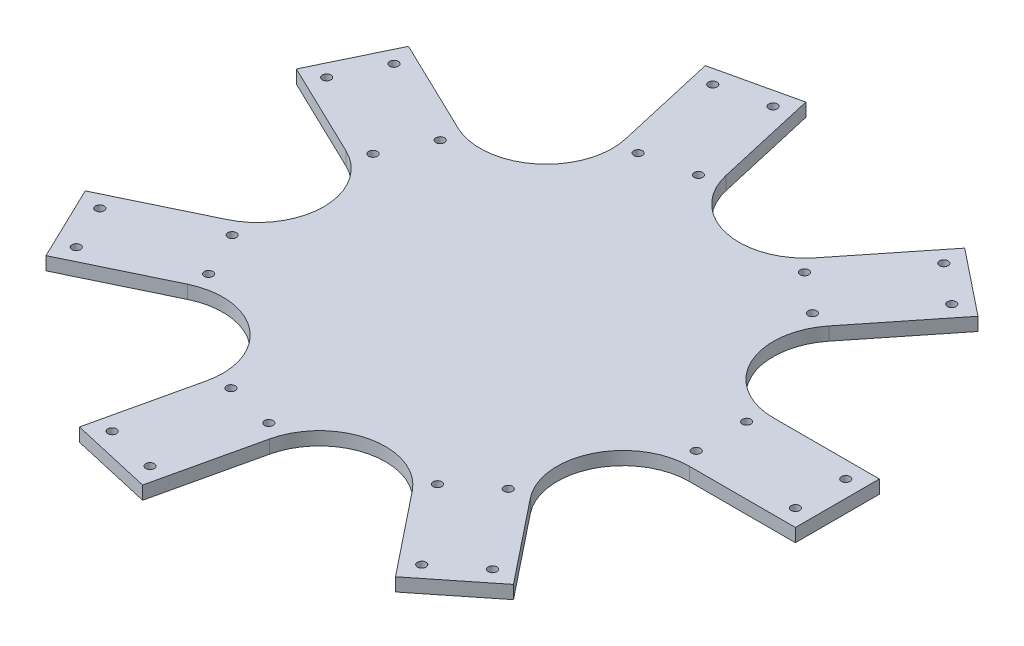
from build123d import *

# Parameters (mm, degrees)
SKETCH3_W           = 250
SKETCH3_H           = 63.5
SKETCH3_R           = 3.25
BOSS_EXTRUDE1_DEPTH = 10
CIRPATTERN1_COUNT   = 7
FILLET1_R           = 50


with BuildPart() as part:
    # Sketch3 → Boss-Extrude1 (new body)
    with BuildSketch(Plane(origin=(0, 0, 0), x_dir=(1, 0, 0), z_dir=(0, 1, 0))):
        with Locations((125, 0)):
            Rectangle(SKETCH3_W, SKETCH3_H)
        with Locations((162.3, 19.05)):
            Circle(SKETCH3_R, mode=Mode.SUBTRACT)
        with Locations((162.3, -19.05)):
            Circle(SKETCH3_R, mode=Mode.SUBTRACT)
        with Locations((237.3, 19.05)):
            Circle(SKETCH3_R, mode=Mode.SUBTRACT)
        with Locations((237.3, -19.05)):
            Circle(SKETCH3_R, mode=Mode.SUBTRACT)
    boss_extrude1 = extrude(amount=BOSS_EXTRUDE1_DEPTH)

    # CirPattern1: Boss-Extrude1 ×7 about axis
    cirpattern1_axis = Axis((0, 0, 0), (0, 1, 0))
    for i in range(1, CIRPATTERN1_COUNT):
        add(boss_extrude1.rotate(cirpattern1_axis, i * 360 / CIRPATTERN1_COUNT))

    # Fillet1
    fillet1_edges = [part.edges().sort_by_distance(p)[0] for p in [
        (65.929554341, 5, 31.75),
        (65.929554341, 5, -31.75),
        (16.283255204, 5, 71.341602418),
        (-45.624667219, 5, 57.211523112),
        (-73.176284653, 5, 0),
        (-45.624667219, 5, -57.211523112),
        (16.283255204, 5, -71.341602418),
    ]]
    fillet(fillet1_edges, radius=FILLET1_R)


solid = part.part
